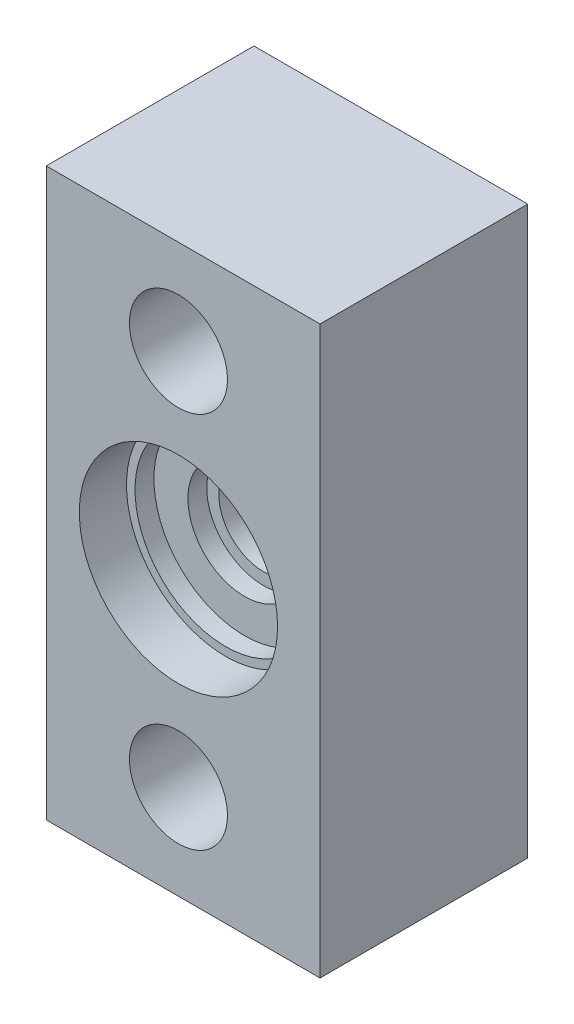
from build123d import *

# Parameters (mm, degrees)
SKETCH1_W               = 15
SKETCH1_H               = 30
BOSS_EXTRUDE1_DEPTH     = 6
SKETCH2_R               = 5.25
CUT_EXTRUDE1_DEPTH      = 2.5
SKETCH4_R               = 4.8
CUT_EXTRUDE3_DEPTH      = 1
SKETCH5_R               = 2.36
CUT_EXTRUDE4_DEPTH      = 4.5
CUT_EXTRUDE4_DEPTH_BACK = 5
CUT_EXTRUDE6_DEPTH      = 7
CUT_EXTRUDE6_DEPTH_BACK = 1
SKETCH11_W              = 14.5
SKETCH11_H              = 30
BOSS_EXTRUDE5_DEPTH     = 5
SKETCH12_R              = 4
CUT_EXTRUDE8_DEPTH      = 5
SKETCH13_R              = 2.595
CUT_EXTRUDE9_DEPTH      = 12
SKETCH14_R              = 3
CUT_EXTRUDE10_DEPTH     = 1


with BuildPart() as part:
    # Sketch1 → Boss-Extrude1 (new body)
    with BuildSketch(Plane.XY):
        Rectangle(SKETCH1_W, SKETCH1_H)
    extrude(amount=BOSS_EXTRUDE1_DEPTH)

    # Sketch2 → Cut-Extrude1 (cut)
    with BuildSketch(Plane.XY.offset(6)):
        Circle(SKETCH2_R)
    extrude(amount=-CUT_EXTRUDE1_DEPTH, mode=Mode.SUBTRACT)

    # Sketch4 → Cut-Extrude3 (cut)
    with BuildSketch(Plane.XY.offset(3.5)):
        Circle(SKETCH4_R)
    extrude(amount=-CUT_EXTRUDE3_DEPTH, mode=Mode.SUBTRACT)

    # Sketch5 → Cut-Extrude4 (cut, two sides)
    with BuildSketch(Plane.XY.offset(2.5)) as cut_extrude4_sk:
        Circle(SKETCH5_R)
    extrude(amount=CUT_EXTRUDE4_DEPTH, mode=Mode.SUBTRACT)
    extrude(cut_extrude4_sk.sketch, amount=-CUT_EXTRUDE4_DEPTH_BACK, mode=Mode.SUBTRACT)

    # Sketch6 → Cut-Extrude6 (cut, two sides)
    with BuildSketch(Plane.XY) as cut_extrude6_sk:
        Polygon((-7, 91.640828326), (-7, 15), (-7, -15), (-7, -91.640828326), (-160.281656652, -91.640828326), (-160.281656652, 91.640828326), align=None)
    extrude(amount=CUT_EXTRUDE6_DEPTH, mode=Mode.SUBTRACT)
    extrude(cut_extrude6_sk.sketch, amount=-CUT_EXTRUDE6_DEPTH_BACK, mode=Mode.SUBTRACT)

    # Sketch11 → Boss-Extrude5 (add)
    with BuildSketch(Plane(origin=(0, 0, 0), x_dir=(-1, 0, 0), z_dir=(0, 0, -1))):
        with Locations((-0.25, 0)):
            Rectangle(SKETCH11_W, SKETCH11_H)
    extrude(amount=BOSS_EXTRUDE5_DEPTH)

    # Sketch12 → Cut-Extrude8 (cut)
    with BuildSketch(Plane(origin=(0, 0, -5), x_dir=(-1, 0, 0), z_dir=(0, 0, -1))):
        Circle(SKETCH12_R)
    extrude(amount=-CUT_EXTRUDE8_DEPTH, mode=Mode.SUBTRACT)

    # Sketch13 → Cut-Extrude9 (cut, through all)
    with BuildSketch(Plane(origin=(0, 0, -5), x_dir=(-1, 0, 0), z_dir=(0, 0, -1))):
        with Locations((0, -10)):
            Circle(SKETCH13_R)
        with Locations((0, 10)):
            Circle(SKETCH13_R)
    extrude(amount=-CUT_EXTRUDE9_DEPTH, mode=Mode.SUBTRACT)

    # Sketch14 → Cut-Extrude10 (cut)
    with BuildSketch(Plane.XY.offset(2.5)):
        Circle(SKETCH14_R)
    extrude(amount=-CUT_EXTRUDE10_DEPTH, mode=Mode.SUBTRACT)


solid = part.part
